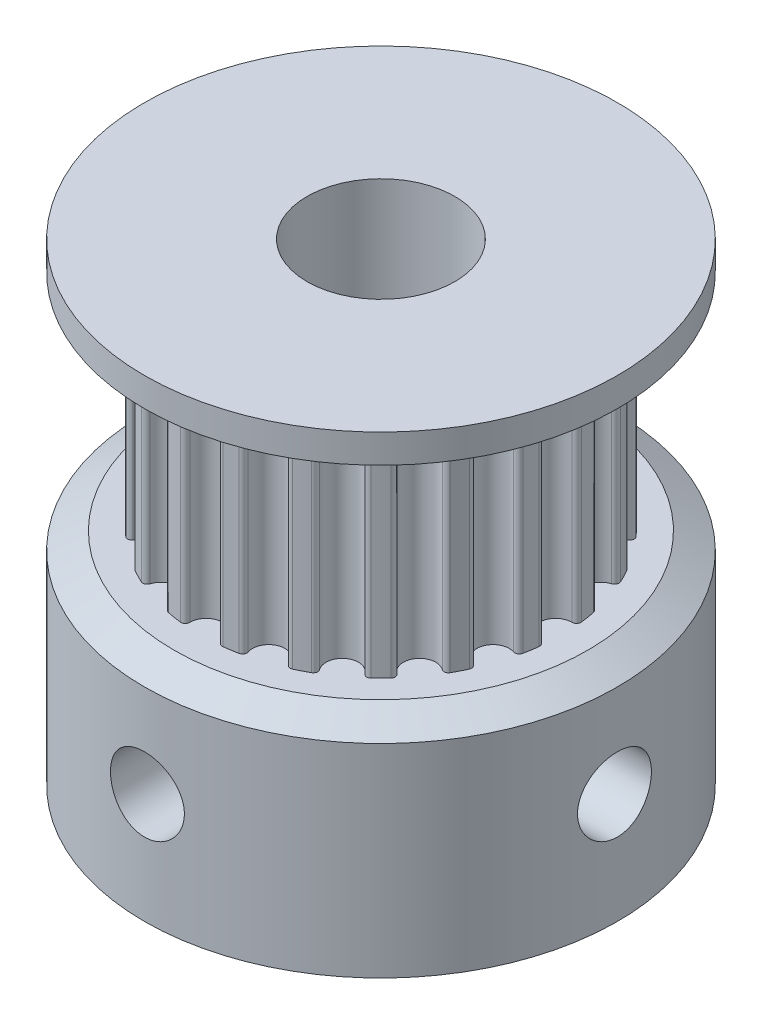
from build123d import *

# Parameters (mm, degrees)
SKETCH_1_R             = 8
SKETCH_1_R_2           = 2.5
EXTRUDE_1_DEPTH        = 7.45
SKETCH_2_R             = 2.5
EXTRUDE_2_DEPTH        = 7
SKETCH_3_R             = 8
SKETCH_3_R_2           = 2.5
EXTRUDE_3_DEPTH        = 1.55
CUT_EXTRUDE_1_REACH    = 10
SKETCH_4_R             = 1.25
CUT_EXTRUDE_2_REACH    = 10
SKETCH_5_R             = 1.25
CHAMFER_1_SIZE         = 1
CHAMFER_1_SIZE2        = 0.577350269
CHAMFER_1_PART_2_SIZE  = 1
CHAMFER_1_PART_2_SIZE2 = 0.577350269


with BuildPart() as part:
    # Sketch 1 → Extrude 1 (new body)
    with BuildSketch(Plane(origin=(0, 0, 0), x_dir=(1, 0, 0), z_dir=(0, 1, 0))):
        Circle(SKETCH_1_R)
        Circle(SKETCH_1_R_2, mode=Mode.SUBTRACT)
    extrude(amount=EXTRUDE_1_DEPTH)

    # Sketch 2 → Extrude 2 (add)
    with BuildSketch(Plane(origin=(0, 7.45, 0), x_dir=(1, 0, 0), z_dir=(0, 1, 0))):
        with BuildLine():
            ThreePointArc((-2.557469435, 5.549004423), (-2.773881953, 5.444049863), (-2.985996064, 5.3306592))
            ThreePointArc((-2.985996064, 5.3306592), (-3.059404709, 5.231014138), (-3.032930262, 5.110113057))
            ThreePointArc((-3.032930262, 5.110113057), (-3.150528952, 4.33633109), (-3.922779328, 4.463599867))
            ThreePointArc((-3.922779328, 4.463599867), (-4.029582035, 4.526139051), (-4.14703464, 4.487115298))
            ThreePointArc((-4.14703464, 4.487115298), (-4.320422433, 4.320422433), (-4.487115298, 4.14703464))
            ThreePointArc((-4.487115298, 4.14703464), (-4.526139051, 4.029582035), (-4.463599867, 3.922779328))
            ThreePointArc((-4.463599867, 3.922779328), (-4.33633109, 3.150528952), (-5.110113057, 3.032930262))
            ThreePointArc((-5.110113057, 3.032930262), (-5.231014138, 3.059404709), (-5.3306592, 2.985996064))
            ThreePointArc((-5.3306592, 2.985996064), (-5.444049863, 2.773881953), (-5.549004423, 2.557469435))
            ThreePointArc((-5.549004423, 2.557469435), (-5.549823367, 2.433706366), (-5.457341217, 2.351456627))
            ThreePointArc((-5.457341217, 2.351456627), (-5.097662927, 1.65633109), (-5.797233315, 1.305376312))
            ThreePointArc((-5.797233315, 1.305376312), (-5.92039813, 1.293194518), (-5.992481697, 1.19258673))
            ThreePointArc((-5.992481697, 1.19258673), (-6.034775761, 0.955814581), (-6.067718334, 0.717561302))
            ThreePointArc((-6.067718334, 0.717561302), (-6.030252304, 0.599602562), (-5.916879985, 0.549956967))
            ThreePointArc((-5.916879985, 0.549956967), (-5.36, 0), (-5.916879985, -0.549956967))
            ThreePointArc((-5.916879985, -0.549956967), (-6.030252304, -0.599602562), (-6.067718334, -0.717561302))
            ThreePointArc((-6.067718334, -0.717561302), (-6.034775761, -0.955814581), (-5.992481697, -1.19258673))
            ThreePointArc((-5.992481697, -1.19258673), (-5.92039813, -1.293194518), (-5.797233315, -1.305376312))
            ThreePointArc((-5.797233315, -1.305376312), (-5.097662927, -1.65633109), (-5.457341217, -2.351456627))
            ThreePointArc((-5.457341217, -2.351456627), (-5.549823367, -2.433706366), (-5.549004423, -2.557469435))
            ThreePointArc((-5.549004423, -2.557469435), (-5.444049863, -2.773881953), (-5.3306592, -2.985996064))
            ThreePointArc((-5.3306592, -2.985996064), (-5.231014138, -3.059404709), (-5.110113057, -3.032930262))
            ThreePointArc((-5.110113057, -3.032930262), (-4.33633109, -3.150528952), (-4.463599867, -3.922779328))
            ThreePointArc((-4.463599867, -3.922779328), (-4.526139051, -4.029582035), (-4.487115298, -4.14703464))
            ThreePointArc((-4.487115298, -4.14703464), (-4.320422433, -4.320422433), (-4.14703464, -4.487115298))
            ThreePointArc((-4.14703464, -4.487115298), (-4.029582035, -4.526139051), (-3.922779328, -4.463599867))
            ThreePointArc((-3.922779328, -4.463599867), (-3.150528952, -4.33633109), (-3.032930262, -5.110113057))
            ThreePointArc((-3.032930262, -5.110113057), (-3.059404709, -5.231014138), (-2.985996064, -5.3306592))
            ThreePointArc((-2.985996064, -5.3306592), (-2.773881953, -5.444049863), (-2.557469435, -5.549004423))
            ThreePointArc((-2.557469435, -5.549004423), (-2.433706366, -5.549823367), (-2.351456627, -5.457341217))
            ThreePointArc((-2.351456627, -5.457341217), (-1.65633109, -5.097662927), (-1.305376312, -5.797233315))
            ThreePointArc((-1.305376312, -5.797233315), (-1.293194518, -5.92039813), (-1.19258673, -5.992481697))
            ThreePointArc((-1.19258673, -5.992481697), (-0.955814581, -6.034775761), (-0.717561302, -6.067718334))
            ThreePointArc((-0.717561302, -6.067718334), (-0.599602562, -6.030252304), (-0.549956967, -5.916879985))
            ThreePointArc((-0.549956967, -5.916879985), (0, -5.36), (0.549956967, -5.916879985))
            ThreePointArc((0.549956967, -5.916879985), (0.599602562, -6.030252304), (0.717561302, -6.067718334))
            ThreePointArc((0.717561302, -6.067718334), (0.955814581, -6.034775761), (1.19258673, -5.992481697))
            ThreePointArc((1.19258673, -5.992481697), (1.293194518, -5.92039813), (1.305376312, -5.797233315))
            ThreePointArc((1.305376312, -5.797233315), (1.65633109, -5.097662927), (2.351456627, -5.457341217))
            ThreePointArc((2.351456627, -5.457341217), (2.433706366, -5.549823367), (2.557469435, -5.549004423))
            ThreePointArc((2.557469435, -5.549004423), (2.773881953, -5.444049863), (2.985996064, -5.3306592))
            ThreePointArc((2.985996064, -5.3306592), (3.059404709, -5.231014138), (3.032930262, -5.110113057))
            ThreePointArc((3.032930262, -5.110113057), (3.150528952, -4.33633109), (3.922779328, -4.463599867))
            ThreePointArc((3.922779328, -4.463599867), (4.029582035, -4.526139051), (4.14703464, -4.487115298))
            ThreePointArc((4.14703464, -4.487115298), (4.320422433, -4.320422433), (4.487115298, -4.14703464))
            ThreePointArc((4.487115298, -4.14703464), (4.526139051, -4.029582035), (4.463599867, -3.922779328))
            ThreePointArc((4.463599867, -3.922779328), (4.33633109, -3.150528952), (5.110113057, -3.032930262))
            ThreePointArc((5.110113057, -3.032930262), (5.231014138, -3.059404709), (5.3306592, -2.985996064))
            ThreePointArc((5.3306592, -2.985996064), (5.444049863, -2.773881953), (5.549004423, -2.557469435))
            ThreePointArc((5.549004423, -2.557469435), (5.549823367, -2.433706366), (5.457341217, -2.351456627))
            ThreePointArc((5.457341217, -2.351456627), (5.097662927, -1.65633109), (5.797233315, -1.305376312))
            ThreePointArc((5.797233315, -1.305376312), (5.92039813, -1.293194518), (5.992481697, -1.19258673))
            ThreePointArc((5.992481697, -1.19258673), (6.034775761, -0.955814581), (6.067718334, -0.717561302))
            ThreePointArc((6.067718334, -0.717561302), (6.030252304, -0.599602562), (5.916879985, -0.549956967))
            ThreePointArc((5.916879985, -0.549956967), (5.36, 0), (5.916879985, 0.549956967))
            ThreePointArc((5.916879985, 0.549956967), (6.030252304, 0.599602562), (6.067718334, 0.717561302))
            ThreePointArc((6.067718334, 0.717561302), (6.034775761, 0.955814581), (5.992481697, 1.19258673))
            ThreePointArc((5.992481697, 1.19258673), (5.92039813, 1.293194518), (5.797233315, 1.305376312))
            ThreePointArc((5.797233315, 1.305376312), (5.097662927, 1.65633109), (5.457341217, 2.351456627))
            ThreePointArc((5.457341217, 2.351456627), (5.549823367, 2.433706366), (5.549004423, 2.557469435))
            ThreePointArc((5.549004423, 2.557469435), (5.444049863, 2.773881953), (5.3306592, 2.985996064))
            ThreePointArc((5.3306592, 2.985996064), (5.231014138, 3.059404709), (5.110113057, 3.032930262))
            ThreePointArc((5.110113057, 3.032930262), (4.33633109, 3.150528952), (4.463599867, 3.922779328))
            ThreePointArc((4.463599867, 3.922779328), (4.526139051, 4.029582035), (4.487115298, 4.14703464))
            ThreePointArc((4.487115298, 4.14703464), (4.320422433, 4.320422433), (4.14703464, 4.487115298))
            ThreePointArc((4.14703464, 4.487115298), (4.029582035, 4.526139051), (3.922779328, 4.463599867))
            ThreePointArc((3.922779328, 4.463599867), (3.150528952, 4.33633109), (3.032930262, 5.110113057))
            ThreePointArc((3.032930262, 5.110113057), (3.059404709, 5.231014138), (2.985996064, 5.3306592))
            ThreePointArc((2.985996064, 5.3306592), (2.773881953, 5.444049863), (2.557469435, 5.549004423))
            ThreePointArc((2.557469435, 5.549004423), (2.433706366, 5.549823367), (2.351456627, 5.457341217))
            ThreePointArc((2.351456627, 5.457341217), (1.65633109, 5.097662927), (1.305376312, 5.797233315))
            ThreePointArc((1.305376312, 5.797233315), (1.293194518, 5.92039813), (1.19258673, 5.992481697))
            ThreePointArc((1.19258673, 5.992481697), (0.955814581, 6.034775761), (0.717561302, 6.067718334))
            ThreePointArc((0.717561302, 6.067718334), (0.599602562, 6.030252304), (0.549956967, 5.916879985))
            ThreePointArc((0.549956967, 5.916879985), (0, 5.36), (-0.549956967, 5.916879985))
            ThreePointArc((-0.549956967, 5.916879985), (-0.599602562, 6.030252304), (-0.717561302, 6.067718334))
            ThreePointArc((-0.717561302, 6.067718334), (-0.955814581, 6.034775761), (-1.19258673, 5.992481697))
            ThreePointArc((-1.19258673, 5.992481697), (-1.293194518, 5.92039813), (-1.305376312, 5.797233315))
            ThreePointArc((-1.305376312, 5.797233315), (-1.65633109, 5.097662927), (-2.351456627, 5.457341217))
            ThreePointArc((-2.351456627, 5.457341217), (-2.433706366, 5.549823367), (-2.557469435, 5.549004423))
        make_face()
        Circle(SKETCH_2_R, mode=Mode.SUBTRACT)
    extrude(amount=EXTRUDE_2_DEPTH)

    # Sketch 3 → Extrude 3 (add)
    with BuildSketch(Plane(origin=(0, 14.45, 0), x_dir=(1, 0, 0), z_dir=(0, 1, 0))):
        Circle(SKETCH_3_R)
        Circle(SKETCH_3_R_2, mode=Mode.SUBTRACT)
    extrude(amount=EXTRUDE_3_DEPTH)

    # Sketch 4 → Cut-Extrude 1 (cut, up to next)
    with BuildSketch(Plane.XY, mode=Mode.PRIVATE) as cut_extrude_1_sk1:
        with Locations((0, 3.725)):
            Circle(SKETCH_4_R)
    cut_extrude_1_tool1 = extrude(cut_extrude_1_sk1.sketch, amount=CUT_EXTRUDE_1_REACH, mode=Mode.PRIVATE) & part.part
    add(cut_extrude_1_tool1.solids().sort_by_distance((0, 3.725, 0))[0], mode=Mode.SUBTRACT)

    # Sketch 5 → Cut-Extrude 2 (cut, up to next)
    with BuildSketch(Plane(origin=(0, 0, 0), x_dir=(0, 0, -1), z_dir=(1, 0, 0)), mode=Mode.PRIVATE) as cut_extrude_2_sk1:
        with Locations((0, 3.725)):
            Circle(SKETCH_5_R)
    cut_extrude_2_tool1 = extrude(cut_extrude_2_sk1.sketch, amount=CUT_EXTRUDE_2_REACH, mode=Mode.PRIVATE) & part.part
    add(cut_extrude_2_tool1.solids().sort_by_distance((0, 3.725, 0))[0], mode=Mode.SUBTRACT)

    # Chamfer 1
    chamfer_1_edges = [part.edges().sort_by_distance(p)[0] for p in [
        (-8, 14.45, 0),
    ]]
    chamfer_1_side = [part.faces().sort_by_distance(p)[0] for p in [
        (-7.77372583, 14.45, 0),
    ]]
    chamfer(chamfer_1_edges, length=CHAMFER_1_SIZE, length2=CHAMFER_1_SIZE2, reference=chamfer_1_side[0])

    # Chamfer 1 part 2
    chamfer_1_part_2_edges = [part.edges().sort_by_distance(p)[0] for p in [
        (-8, 7.45, 0),
    ]]
    chamfer_1_part_2_side = [part.faces().sort_by_distance(p)[0] for p in [
        (-7.77372583, 7.45, 0),
    ]]
    chamfer(chamfer_1_part_2_edges, length=CHAMFER_1_PART_2_SIZE, length2=CHAMFER_1_PART_2_SIZE2, reference=chamfer_1_part_2_side[0])


solid = part.part
